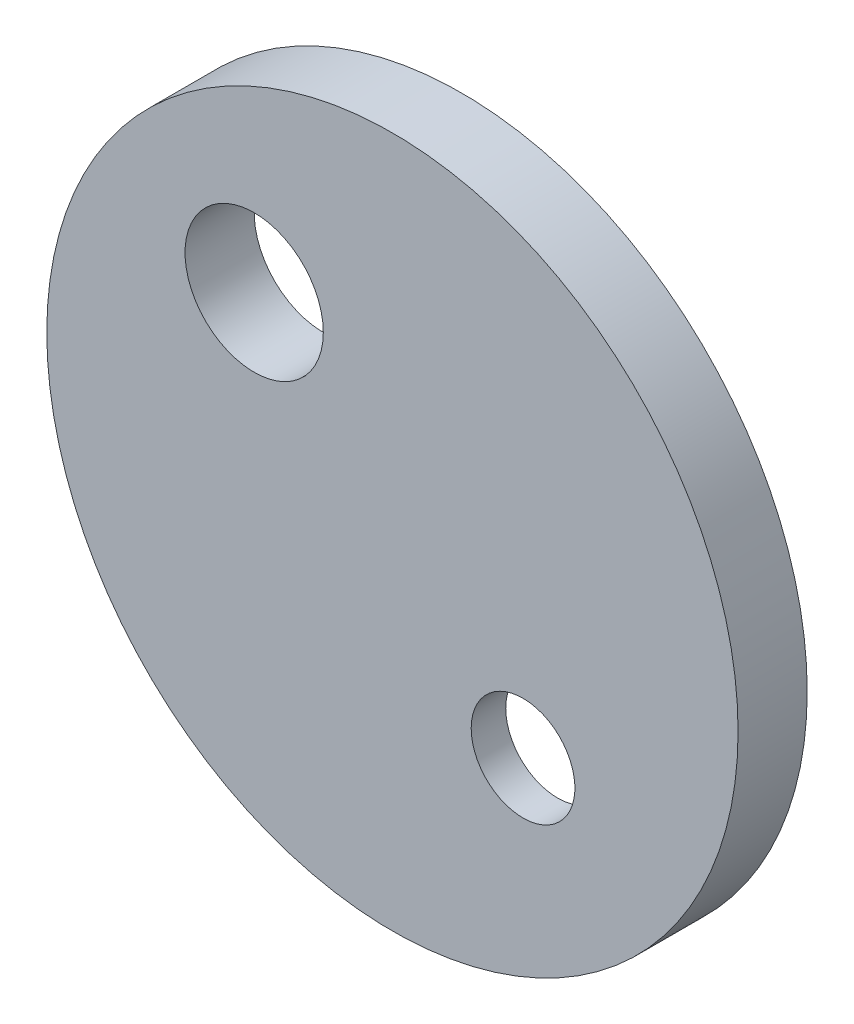
from build123d import *

# Parameters (mm, degrees)
CROQUIS1_R                 = 2.5
CROQUIS1_R_2               = 0.5
SALIENTE_EXTRUIR1_DEPTH    = 0.5
CROQUIS2_R                 = 0.75
CORTAR_EXTRUIR1_DEPTH      = 0.25
TALADRO_ROSCADO_M1X0_251_D = 0.75


with BuildPart() as part:
    # Croquis1 → Saliente-Extruir1 (new body)
    with BuildSketch(Plane.XY):
        Circle(CROQUIS1_R)
        with Locations((-1, 1)):
            Circle(CROQUIS1_R_2, mode=Mode.SUBTRACT)
    extrude(amount=SALIENTE_EXTRUIR1_DEPTH)

    # Croquis2 → Cortar-Extruir1 (cut)
    with BuildSketch(Plane(origin=(0, 0, 0), x_dir=(-1, 0, 0), z_dir=(0, 0, -1))):
        with Locations((-0.944543648, -0.944543648)):
            Circle(CROQUIS2_R)
    extrude(amount=-CORTAR_EXTRUIR1_DEPTH, mode=Mode.SUBTRACT)

    # Taladro roscado M1x0.251 (through all)
    with Locations(Plane(origin=(0, 0, 0.25), x_dir=(-1, 0, 0), z_dir=(0, 0, -1))):
        with Locations((-0.944543648, -0.944543648)):
            Hole(TALADRO_ROSCADO_M1X0_251_D / 2)


solid = part.part
